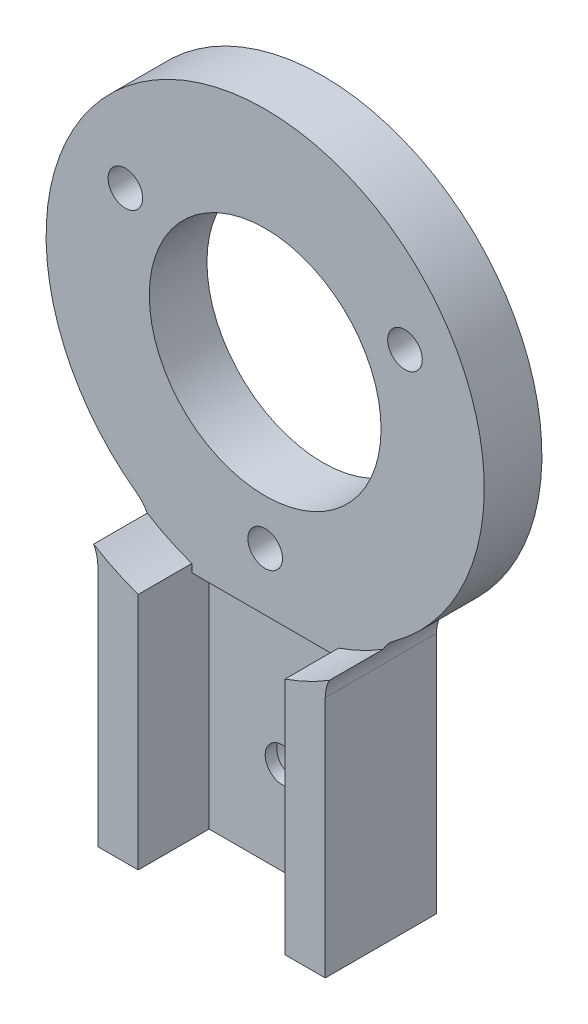
from build123d import *

# Parameters (mm, degrees)
SKETCH1_R           = 10
BOSS_EXTRUDE1_DEPTH = 5
SKETCH5_W           = 12.72
SKETCH5_H           = 1.5
CUT_EXTRUDE1_DEPTH  = 20
SKETCH18_R          = 1.5
CUT_EXTRUDE6_DEPTH  = 6
SKETCH10_W          = 3.5
SKETCH10_H          = 20
BOSS_EXTRUDE3_DEPTH = 4.65
SKETCH15_R          = 3
CUT_EXTRUDE4_DEPTH  = 2.5
SKETCH19_R          = 10.05
CUT_EXTRUDE7_DEPTH  = 10.65
BOSS_EXTRUDE6_DEPTH = 4.65
SKETCH24_R          = 1.5
CUT_EXTRUDE8_DEPTH  = 7
SKETCH25_R          = 3
CUT_EXTRUDE9_DEPTH  = 2.5
FILLET5_R           = 3.175


with BuildPart() as part:
    # Sketch1 → Boss-Extrude1 (new body)
    with BuildSketch(Plane.XY):
        with BuildLine():
            Line((9.86, -39), (-9.86, -39))
            Line((-9.86, -39), (-9.86, -16.241317681))
            ThreePointArc((-9.86, -16.241317681), (0, 19), (9.86, -16.241317681))
            Line((9.86, -16.241317681), (9.86, -39))
        make_face()
        Circle(SKETCH1_R, mode=Mode.SUBTRACT)
    extrude(amount=BOSS_EXTRUDE1_DEPTH)

    # Sketch5 → Cut-Extrude1 (cut)
    with BuildSketch(Plane.XZ.offset(39)):
        with Locations((0, 4.25)):
            Rectangle(SKETCH5_W, SKETCH5_H)
    extrude(amount=-CUT_EXTRUDE1_DEPTH, mode=Mode.SUBTRACT)

    # Sketch18 → Cut-Extrude6 (cut, through all)
    with BuildSketch(Plane.XY.offset(5)):
        with Locations((0, -14)):
            Circle(SKETCH18_R)
        with Locations((-12.124355653, 7)):
            Circle(SKETCH18_R)
        with Locations((12.124355653, 7)):
            Circle(SKETCH18_R)
    extrude(amount=-CUT_EXTRUDE6_DEPTH, mode=Mode.SUBTRACT)

    # Sketch10 → Boss-Extrude3 (add)
    with BuildSketch(Plane.XY.offset(5)):
        with Locations((-8.11, -29)):
            Rectangle(SKETCH10_W, SKETCH10_H)
        with Locations((8.11, -29)):
            Rectangle(SKETCH10_W, SKETCH10_H)
    extrude(amount=BOSS_EXTRUDE3_DEPTH)

    # Sketch15 → Cut-Extrude4 (cut)
    with BuildSketch(Plane(origin=(0, 0, 0), x_dir=(-1, 0, 0), z_dir=(0, 0, -1))):
        with Locations((0, -14)):
            Circle(SKETCH15_R)
        with Locations((-12.124355653, 7)):
            Circle(SKETCH15_R)
        with Locations((12.124355653, 7)):
            Circle(SKETCH15_R)
    extrude(amount=-CUT_EXTRUDE4_DEPTH, mode=Mode.SUBTRACT)

    # Sketch19 → Cut-Extrude7 (cut, through all)
    with BuildSketch(Plane(origin=(0, 0, 0), x_dir=(-1, 0, 0), z_dir=(0, 0, -1))):
        Circle(SKETCH19_R)
    extrude(amount=-CUT_EXTRUDE7_DEPTH, mode=Mode.SUBTRACT)

    # Sketch23 → Boss-Extrude6 (add)
    with BuildSketch(Plane.XY.offset(5)):
        with BuildLine():
            Line((9.86, -16.678459911), (9.86, -19))
            Line((9.86, -19), (6.36, -19))
            Line((6.36, -19), (6.36, -18.301394073))
            ThreePointArc((6.36, -18.301394073), (8.150495618, -17.577259348), (9.86, -16.678459911))
        make_face()
    boss_extrude6 = extrude(amount=BOSS_EXTRUDE6_DEPTH)

    # Mirror1: Boss-Extrude6 across plane
    add(boss_extrude6.mirror(Plane(origin=(0, 0, 0), x_dir=(0, 0, 1), z_dir=(1, 0, 0))))

    # Sketch24 → Cut-Extrude8 (cut)
    with BuildSketch(Plane(origin=(0, 0, 0), x_dir=(-1, 0, 0), z_dir=(0, 0, -1))):
        with Locations((0, -31)):
            Circle(SKETCH24_R)
    extrude(amount=-CUT_EXTRUDE8_DEPTH, mode=Mode.SUBTRACT)

    # Sketch25 → Cut-Extrude9 (cut)
    with BuildSketch(Plane(origin=(0, 0, 0), x_dir=(-1, 0, 0), z_dir=(0, 0, -1))):
        with Locations((0, -31)):
            Circle(SKETCH25_R)
    extrude(amount=-CUT_EXTRUDE9_DEPTH, mode=Mode.SUBTRACT)

    # Fillet5
    fillet5_edges = [part.edges().sort_by_distance(p)[0] for p in [
        (9.86, -16.241317681, 2.5),
        (-9.86, -16.241317681, 2.5),
    ]]
    fillet(fillet5_edges, radius=FILLET5_R)


solid = part.part
